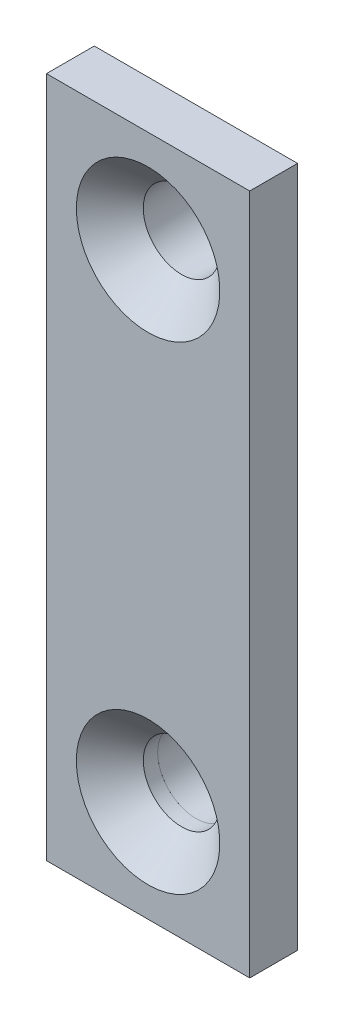
from build123d import *

# Parameters (mm, degrees)
SKETCH1_W             = 4.75
SKETCH1_H             = 4.5
SKETCH1_R             = 1.6
BOSS_EXTRUDE1_DEPTH   = 2
BOSS_EXTRUDE1_2_DEPTH = 2
BOSS_EXTRUDE2_START   = 2
SKETCH1_3_W           = 28.5
SKETCH1_3_H           = 8.5
SKETCH1_3_W_2         = 24.5
SKETCH1_3_H_2         = 4.5
SKETCH1_3_R           = 1.6
SKETCH1_3_W_3         = 15
SKETCH1_3_W_4         = 4.75
BOSS_EXTRUDE2_DEPTH   = 2
CHAMFER1_SIZE         = 1.4


with BuildPart() as part:
    # Sketch1 → Boss-Extrude1 (new body)
    with BuildSketch(Plane(origin=(0, 0, 0), x_dir=(0, 1, 0), z_dir=(0, 0, 1))):
        with Locations((-9.875, 0)):
            Rectangle(SKETCH1_W, SKETCH1_H)
        with Locations((-10, 0)):
            Circle(SKETCH1_R, mode=Mode.SUBTRACT)
    extrude(amount=BOSS_EXTRUDE1_DEPTH)


with BuildPart() as body_2:
    # Sketch1 → Boss-Extrude1 2 (new body)
    with BuildSketch(Plane(origin=(0, 0, 0), x_dir=(0, 1, 0), z_dir=(0, 0, 1))):
        with Locations((9.875, 0)):
            Rectangle(SKETCH1_W, SKETCH1_H)
        with Locations((10, 0)):
            Circle(SKETCH1_R, mode=Mode.SUBTRACT)
    extrude(amount=BOSS_EXTRUDE1_2_DEPTH)

    # Sketch1_3 → Boss-Extrude2 (add)
    with BuildSketch(Plane(origin=(0, 0, 0), x_dir=(0, 1, 0), z_dir=(0, 0, 1)).offset(BOSS_EXTRUDE2_START)):
        Rectangle(SKETCH1_3_W, SKETCH1_3_H)
        Rectangle(SKETCH1_3_W_2, SKETCH1_3_H_2, mode=Mode.SUBTRACT)
        Rectangle(SKETCH1_3_W_2, SKETCH1_3_H_2)
        with Locations((10, 0)):
            Circle(SKETCH1_3_R, mode=Mode.SUBTRACT)
        with Locations((-10, 0)):
            Circle(SKETCH1_3_R, mode=Mode.SUBTRACT)
        Rectangle(SKETCH1_3_W_3, SKETCH1_3_H_2)
        with Locations((-9.875, 0)):
            Rectangle(SKETCH1_3_W_4, SKETCH1_3_H_2)
        with Locations((-10, 0)):
            Circle(SKETCH1_3_R, mode=Mode.SUBTRACT)
    extrude(amount=BOSS_EXTRUDE2_DEPTH)

    # Chamfer1
    chamfer1_edges = [body_2.edges().sort_by_distance(p)[0] for p in [
        (0, -11.6, 4),
        (0, 8.4, 4),
    ]]
    chamfer(chamfer1_edges, length=CHAMFER1_SIZE)


solid = Compound([part.part, body_2.part])
